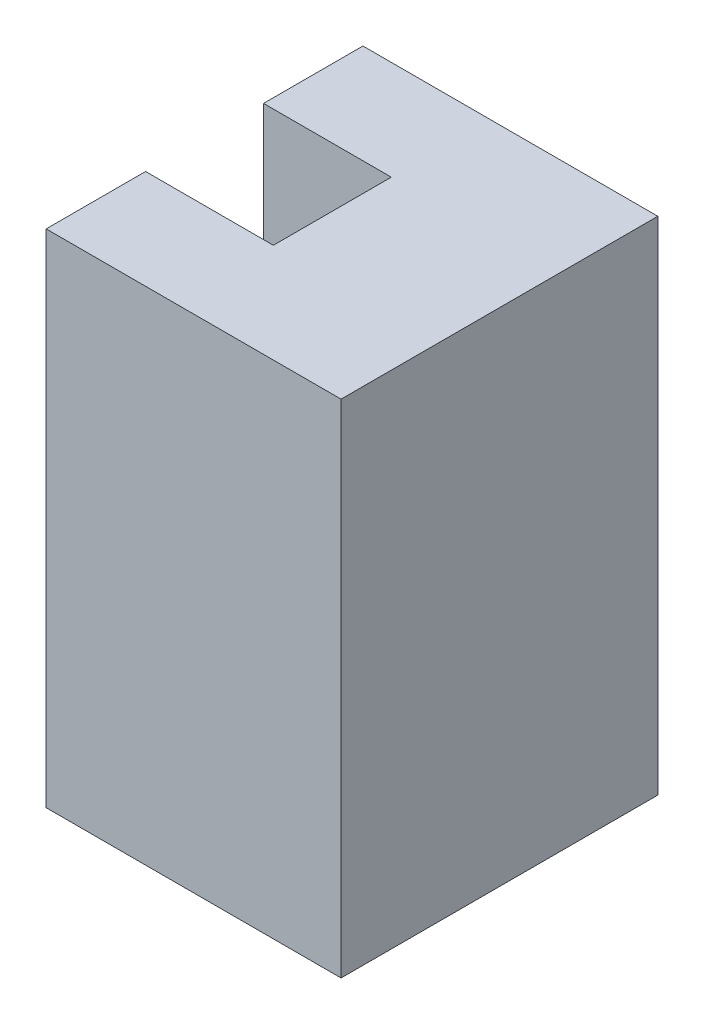
from build123d import *

# Parameters (mm, degrees)
BOSS_EXTRUDE1_DEPTH = 5.5
SKETCH2_W           = 15
SKETCH2_H           = 16.1125
BOSS_EXTRUDE2_DEPTH = 20
SKETCH3_W           = 6
SKETCH3_H           = 18
CUT_EXTRUDE1_DEPTH  = 6.5


with BuildPart() as part:
    # Sketch1 → Boss-Extrude1 (new body)
    with BuildSketch(Plane(origin=(0, 0, 0), x_dir=(1, 0, 0), z_dir=(0, 1, 0))):
        Polygon((0, 5.55625), (0, 8.05625), (15, 8.05625), (15, -8.05625), (0, -8.05625), (0, -5.55625), (3.207902433, -5.55625), (6.415804866, 0), (3.207902433, 5.55625), align=None)
    extrude(amount=BOSS_EXTRUDE1_DEPTH)

    # Sketch2 → Boss-Extrude2 (add)
    with BuildSketch(Plane(origin=(0, 5.5, 0), x_dir=(1, 0, 0), z_dir=(0, 1, 0))):
        with Locations((7.5, 0)):
            Rectangle(SKETCH2_W, SKETCH2_H)
    extrude(amount=BOSS_EXTRUDE2_DEPTH)

    # Sketch3 → Cut-Extrude1 (cut)
    with BuildSketch(Plane.ZY):
        with Locations((0, 16.5)):
            Rectangle(SKETCH3_W, SKETCH3_H)
    extrude(amount=-CUT_EXTRUDE1_DEPTH, mode=Mode.SUBTRACT)


solid = part.part
